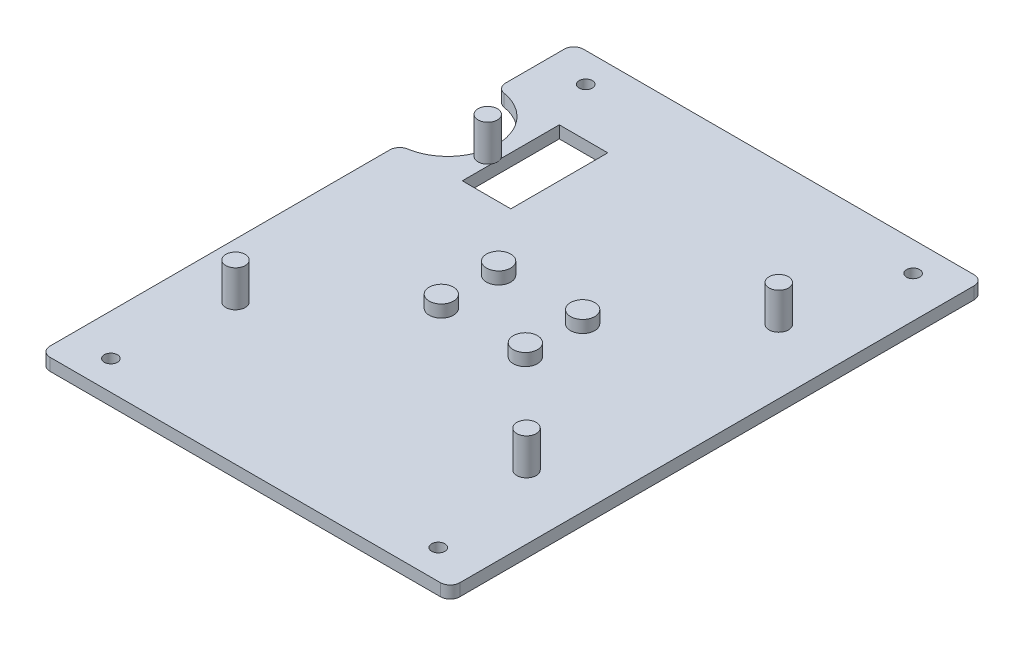
from build123d import *

# Parameters (mm, degrees)
SKETCH1_W           = 107.315
SKETCH1_H           = 139.7
SKETCH1_R           = 1.7272
BOSS_EXTRUDE1_DEPTH = 3.2004
SKETCH2_W           = 12.7
SKETCH2_H           = 25.4
CUT_EXTRUDE1_DEPTH  = 3.2004
SKETCH3_R           = 1.1303
CUT_EXTRUDE2_DEPTH  = 3.2004
FILLET1_R           = 2.54
SKETCH4_R           = 1.02489
CUT_EXTRUDE3_DEPTH  = 3.2004
SKETCH5_R           = 2.54
BOSS_EXTRUDE2_DEPTH = 9.525
SKETCH6_R           = 3.175
BOSS_EXTRUDE3_DEPTH = 3.2004


with BuildPart() as part:
    # Sketch1 → Boss-Extrude1 (new body)
    with BuildSketch(Plane(origin=(0, 0, 0), x_dir=(1, 0, 0), z_dir=(0, 1, 0))):
        with Locations((53.6575, 69.85)):
            Rectangle(SKETCH1_W, SKETCH1_H)
        with Locations((10.795, 132.0165)):
            Circle(SKETCH1_R, mode=Mode.SUBTRACT)
        with Locations((96.52, 132.0165)):
            Circle(SKETCH1_R, mode=Mode.SUBTRACT)
        with Locations((96.52, 7.6835)):
            Circle(SKETCH1_R, mode=Mode.SUBTRACT)
        with Locations((10.795, 7.6835)):
            Circle(SKETCH1_R, mode=Mode.SUBTRACT)
    extrude(amount=BOSS_EXTRUDE1_DEPTH)

    # Sketch2 → Cut-Extrude1 (cut)
    with BuildSketch(Plane(origin=(0, 3.2004, 0), x_dir=(1, 0, 0), z_dir=(0, 1, 0))):
        with Locations((22.86, 106.68)):
            Rectangle(SKETCH2_W, SKETCH2_H)
        with BuildLine():
            Line((0, 119.505365836), (0, 93.854634164))
            ThreePointArc((0, 93.854634164), (12.825365836, 106.68), (0, 119.505365836))
        make_face()
    extrude(amount=-CUT_EXTRUDE1_DEPTH, mode=Mode.SUBTRACT)

    # Sketch3 → Cut-Extrude2 (cut)
    with BuildSketch(Plane(origin=(0, 3.2004, 0), x_dir=(1, 0, 0), z_dir=(0, 1, 0))):
        with Locations((90.4875, 102.87)):
            Circle(SKETCH3_R)
        with Locations((90.4875, 36.83)):
            Circle(SKETCH3_R)
        with Locations((14.2875, 36.83)):
            Circle(SKETCH3_R)
        with Locations((14.2875, 102.87)):
            Circle(SKETCH3_R)
    extrude(amount=-CUT_EXTRUDE2_DEPTH, mode=Mode.SUBTRACT)

    # Fillet1
    fillet1_edges = [part.edges().sort_by_distance(p)[0] for p in [
        (0, 1.6002, -119.505365836),
        (0, 1.6002, -93.854634164),
        (0, 1.6002, -139.7),
        (107.315, 1.6002, -139.7),
        (107.315, 1.6002, 0),
        (0, 1.6002, 0),
    ]]
    fillet(fillet1_edges, radius=FILLET1_R)

    # Sketch4 → Cut-Extrude3 (cut)
    with BuildSketch(Plane(origin=(0, 3.2004, 0), x_dir=(1, 0, 0), z_dir=(0, 1, 0))):
        with Locations((64.6575, 77.35)):
            Circle(SKETCH4_R)
        with Locations((64.6575, 62.35)):
            Circle(SKETCH4_R)
        with Locations((42.6575, 77.35)):
            Circle(SKETCH4_R)
        with Locations((42.6575, 62.35)):
            Circle(SKETCH4_R)
    extrude(amount=-CUT_EXTRUDE3_DEPTH, mode=Mode.SUBTRACT)

    # Sketch5 → Boss-Extrude2 (add)
    with BuildSketch(Plane(origin=(0, 3.2004, 0), x_dir=(1, 0, 0), z_dir=(0, 1, 0))):
        with Locations((90.4875, 102.87)):
            Circle(SKETCH5_R)
        with Locations((90.4875, 36.83)):
            Circle(SKETCH5_R)
        with Locations((14.2875, 36.83)):
            Circle(SKETCH5_R)
        with Locations((14.2875, 102.87)):
            Circle(SKETCH5_R)
    extrude(amount=BOSS_EXTRUDE2_DEPTH)

    # Sketch6 → Boss-Extrude3 (add)
    with BuildSketch(Plane(origin=(0, 3.2004, 0), x_dir=(1, 0, 0), z_dir=(0, 1, 0))):
        with Locations((64.6575, 77.35)):
            Circle(SKETCH6_R)
        with Locations((64.6575, 62.35)):
            Circle(SKETCH6_R)
        with Locations((42.6575, 62.35)):
            Circle(SKETCH6_R)
        with Locations((42.6575, 77.35)):
            Circle(SKETCH6_R)
    extrude(amount=BOSS_EXTRUDE3_DEPTH)


solid = part.part
